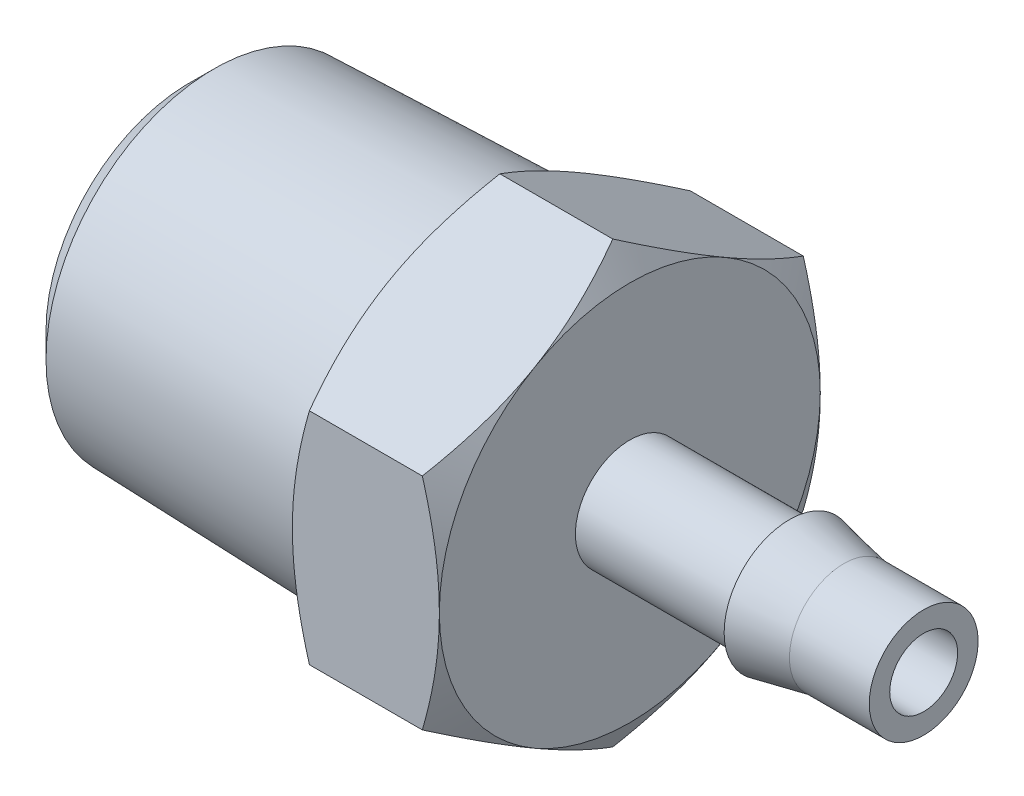
from build123d import *

# Parameters (mm, degrees)
HEX_START               = 10.715625
HEX_HT_DEPTH            = 2.143125
SKETCH2_R               = 5.1435
EXTRUDE_L4_DEPTH        = 8.5725
EXTRUDE_L4_DRAFT        = -1.783333333
SKETCH9_W               = 12.85875
SKETCH9_H               = 0.5969
SKETCH11_OUTSIDE_W      = 75.416
SKETCH11_OUTSIDE_H      = 77.136
SKETCH11_OUTSIDE_R      = 5.55625
CUT_EXTRUDE3_DEPTH      = 16.407203436
CUT_EXTRUDE3_DRAFT      = -60
SKETCH12_OUTSIDE_W      = 75.416
SKETCH12_OUTSIDE_H      = 77.136
SKETCH12_OUTSIDE_R      = 5.55625
CUT_EXTRUDE5_DEPTH      = 16.407203436
CUT_EXTRUDE5_DRAFT      = -60
SKETCH14_R              = 0.9906
CUT_EXTRUDE6_DEPTH      = 16.407203436
CUT_EXTRUDE6_DEPTH_BACK = 16.407203436
SKETCH19_R              = 3.60045
CUT_EXTRUDE7_DEPTH      = 10.715625
CHAMFER1_SIZE           = 0.257175


with BuildPart() as part:
    # Sketch8 → Hex ht (new, symmetric)
    with BuildSketch(Plane(origin=(-10.715625, 0, 0), x_dir=(0, 0, -1), z_dir=(1, 0, 0)).offset(HEX_START)):
        Polygon((0, 6.415804866), (-5.55625, 3.207902433), (-5.55625, -3.207902433), (0, -6.415804866), (5.55625, -3.207902433), (5.55625, 3.207902433), align=None)
    extrude(amount=HEX_HT_DEPTH, both=True)


with BuildPart() as body_2:
    # Sketch2 → Extrude L4 (with draft: the straight prism first)
    with BuildSketch(Plane(origin=(-2.143125, 0, 0), x_dir=(0, 0, -1), z_dir=(1, 0, 0))):
        Circle(SKETCH2_R)
    extrude(amount=-EXTRUDE_L4_DEPTH)
    # Extrude L4: the draft: its side faces are tilted about the plane it starts from
    extrude_l4_sides = [body_2.faces().sort_by_distance(p)[0] for p in [
        (-6.429375, 0, 5.1435),
    ]]
    draft(extrude_l4_sides, Plane(origin=(-2.143125, 0, 0), x_dir=(0, 0, -1), z_dir=(1, 0, 0)), EXTRUDE_L4_DRAFT)

    # Sketch6 → Cut-Revolve1 (revolve, cut)
    with BuildSketch(Plane.XY, mode=Mode.PRIVATE) as cut_revolve1_sk:
        Polygon((-9.987395966, -4.899267892), (-10.715625, -4.171038858), (-10.715625, -4.876594414), align=None)
    revolve(cut_revolve1_sk.sketch.rotate(Axis((-10.715625, 0, 0), (1, 0, 0)), 90), axis=Axis((-10.715625, 0, 0), (1, 0, 0)), mode=Mode.SUBTRACT)

    # Combine2: union part
    add(part.part)

    # Sketch9 → Revolve1 (revolve)
    with BuildSketch(Plane.XY, mode=Mode.PRIVATE) as revolve1_sk:
        with Locations((4.28625, 1.28905)):
            Rectangle(SKETCH9_W, SKETCH9_H)
    revolve(revolve1_sk.sketch.rotate(Axis((0, 0, 0), (1, 0, 0)), 90), axis=Axis((0, 0, 0), (1, 0, 0)))

    # Sketch13 → Revolve2 (revolve)
    with BuildSketch(Plane.XY, mode=Mode.PRIVATE) as revolve2_sk:
        Polygon((8.387291667, 1.5875), (6.799791667, 1.905), (6.799791667, 1.5875), align=None)
    revolve(revolve2_sk.sketch.rotate(Axis((-10.715625, 0, 0), (1, 0, 0)), 90), axis=Axis((-10.715625, 0, 0), (1, 0, 0)))

    # Sketch17 → Revolve3 (revolve)
    with BuildSketch(Plane.XY, mode=Mode.PRIVATE) as revolve3_sk:
        Polygon((-2.143125, 1.905), (-1.593198869, 1.5875), (-2.143125, 1.5875), align=None)
    revolve(revolve3_sk.sketch.rotate(Axis((-10.715625, 0, 0), (1, 0, 0)), 270), axis=Axis((-10.715625, 0, 0), (1, 0, 0)))


with BuildPart() as cut_extrude3_tool:
    # Sketch11 outside → Cut-Extrude3 (with draft: the straight prism first)
    with BuildSketch(Plane(origin=(2.143125, 0, 0), x_dir=(0, 0, -1), z_dir=(1, 0, 0))):
        Rectangle(SKETCH11_OUTSIDE_W, SKETCH11_OUTSIDE_H)
        Circle(SKETCH11_OUTSIDE_R, mode=Mode.SUBTRACT)
    extrude(amount=-CUT_EXTRUDE3_DEPTH)
    # Cut-Extrude3: the draft: its side faces are tilted about the plane it starts from
    cut_extrude3_sides = [cut_extrude3_tool.faces().sort_by_distance(p)[0] for p in [
        (-6.060476718, -38.568, 0),
        (-6.060476718, 0, -37.708),
        (-6.060476718, 38.568, 0),
        (-6.060476718, 0, 37.708),
        (-6.060476718, 0, 5.55625),
    ]]
    draft(cut_extrude3_sides, Plane(origin=(2.143125, 0, 0), x_dir=(0, 0, -1), z_dir=(1, 0, 0)), CUT_EXTRUDE3_DRAFT)


with BuildPart() as body_2_1:
    add(body_2.part)

    # Cut-Extrude3: cut by cut_extrude3_tool
    add(cut_extrude3_tool.part, mode=Mode.SUBTRACT)


with BuildPart() as cut_extrude5_tool:
    # Sketch12 outside → Cut-Extrude5 (with draft: the straight prism first)
    with BuildSketch(Plane.ZY.offset(2.143125)):
        Rectangle(SKETCH12_OUTSIDE_W, SKETCH12_OUTSIDE_H)
        Circle(SKETCH12_OUTSIDE_R, mode=Mode.SUBTRACT)
    extrude(amount=-CUT_EXTRUDE5_DEPTH)
    # Cut-Extrude5: the draft: its side faces are tilted about the plane it starts from
    cut_extrude5_sides = [cut_extrude5_tool.faces().sort_by_distance(p)[0] for p in [
        (6.060476718, -38.568, 0),
        (6.060476718, 0, 37.708),
        (6.060476718, 38.568, 0),
        (6.060476718, 0, -37.708),
        (6.060476718, 0, -5.55625),
    ]]
    draft(cut_extrude5_sides, Plane.ZY.offset(2.143125), CUT_EXTRUDE5_DRAFT)


with BuildPart() as body_2_2:
    add(body_2_1.part)

    # Cut-Extrude5: cut by cut_extrude5_tool
    add(cut_extrude5_tool.part, mode=Mode.SUBTRACT)

    # Sketch14 → Cut-Extrude6 (cut, two sides)
    with BuildSketch(Plane.ZY.offset(2.143125)) as cut_extrude6_sk:
        Circle(SKETCH14_R)
    extrude(amount=CUT_EXTRUDE6_DEPTH, mode=Mode.SUBTRACT)
    extrude(cut_extrude6_sk.sketch, amount=-CUT_EXTRUDE6_DEPTH_BACK, mode=Mode.SUBTRACT)

    # Sketch19 → Cut-Extrude7 (cut)
    with BuildSketch(Plane.ZY.offset(10.715625)):
        Circle(SKETCH19_R)
    extrude(amount=-CUT_EXTRUDE7_DEPTH, mode=Mode.SUBTRACT)

    # Chamfer1
    chamfer1_edges = [body_2_2.edges().sort_by_distance(p)[0] for p in [
        (-10.715625, 0, -3.60045),
    ]]
    chamfer(chamfer1_edges, length=CHAMFER1_SIZE)


solid = body_2_2.part
